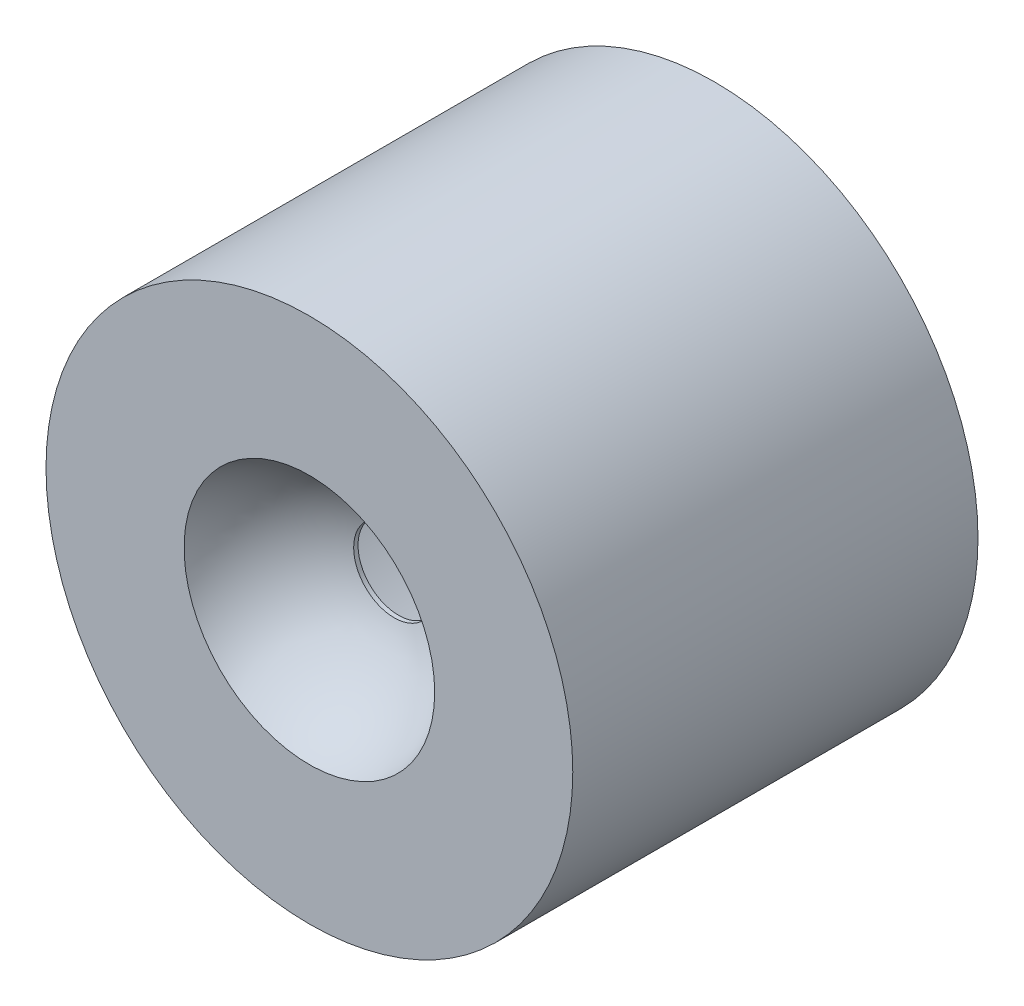
from build123d import *

# Parameters (mm, degrees)
SKETCH2_R           = 32.5
BOSS_EXTRUDE1_DEPTH = 60
CUT_REVOLVE1_ANGLE  = 180
CUT_EXTRUDE1_REACH  = 12
SKETCH5_W           = 97.630906447
SKETCH5_H           = 85.301230118
SKETCH7_R           = 30
CUT_EXTRUDE3_DEPTH  = 39
SKETCH8_R           = 1
BOSS_EXTRUDE2_DEPTH = 5
SKETCH9_R           = 5
CUT_EXTRUDE4_DEPTH  = 1


with BuildPart() as part:
    # Sketch2 → Boss-Extrude1 (new body)
    with BuildSketch(Plane.XY):
        Circle(SKETCH2_R)
    extrude(amount=BOSS_EXTRUDE1_DEPTH)

    # Sketch4 → Cut-Revolve1 (revolve, cut)
    with BuildSketch(Plane.XY.offset(55)):
        with BuildLine():
            Line((-16.25, 0), (16.25, 0))
            ThreePointArc((16.25, 0), (0, 16.25), (-16.25, 0))
        make_face()
    revolve(axis=Axis((-16.25, 0, 55), (-1, 0, 0)), revolution_arc=CUT_REVOLVE1_ANGLE, mode=Mode.SUBTRACT)

    # Sketch5 → Cut-Extrude1 (cut, up to next)
    with BuildSketch(Plane.XY.offset(50), mode=Mode.PRIVATE) as cut_extrude1_sk1:
        with Locations((-1.59772985, 0.365427289)):
            Rectangle(SKETCH5_W, SKETCH5_H)
    cut_extrude1_tool1 = extrude(cut_extrude1_sk1.sketch, amount=CUT_EXTRUDE1_REACH, mode=Mode.PRIVATE) & part.part
    add(cut_extrude1_tool1.solids().sort_by_distance((-1.59773, 0.365427, 50))[0], mode=Mode.SUBTRACT)

    # Sketch7 → Cut-Extrude3 (cut)
    with BuildSketch(Plane(origin=(0, 0, 0), x_dir=(-1, 0, 0), z_dir=(0, 0, -1))):
        Circle(SKETCH7_R)
    extrude(amount=-CUT_EXTRUDE3_DEPTH, mode=Mode.SUBTRACT)

    # Sketch8 → Boss-Extrude2 (add)
    with BuildSketch(Plane(origin=(0, 0, 39), x_dir=(-1, 0, 0), z_dir=(0, 0, -1))):
        with Locations((17.5, -9)):
            Circle(SKETCH8_R)
        with Locations((-17.5, -9)):
            Circle(SKETCH8_R)
    extrude(amount=BOSS_EXTRUDE2_DEPTH)

    # Sketch9 → Cut-Extrude4 (cut)
    with BuildSketch(Plane(origin=(0, 0, 39), x_dir=(-1, 0, 0), z_dir=(0, 0, -1))):
        Circle(SKETCH9_R)
    extrude(amount=-CUT_EXTRUDE4_DEPTH, mode=Mode.SUBTRACT)


solid = part.part
